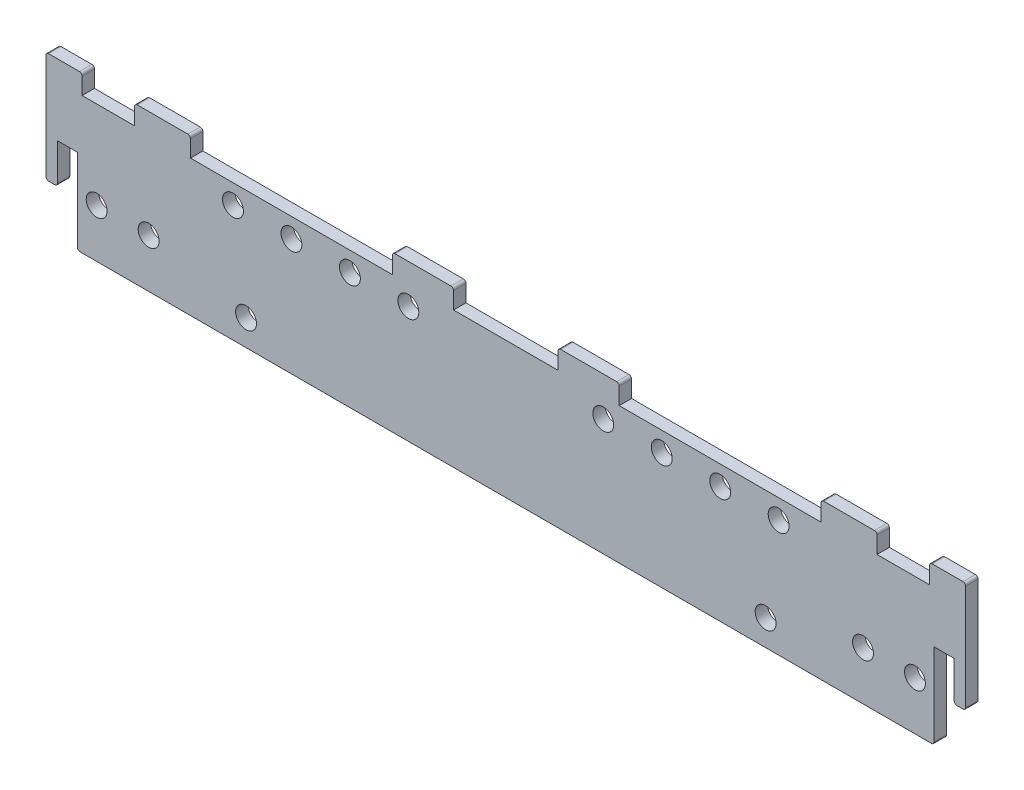
from build123d import *

# Parameters (mm, degrees)
SKETCH41_R                  = 2.5527
BACK_PLATE_EXTRUDE_DEPTH    = 3.0226
SKETCH71_W                  = 8.89
SKETCH71_H                  = 4.7625
SKETCH71_W_2                = 13.79855
SKETCH71_W_3                = 15.09395
BOSS_EXTRUDE26_DEPTH        = 3.0226
SKETCH91_W                  = 4.9022
SKETCH91_H                  = 20.7645
SKETCH91_W_2                = 12.8524
SKETCH91_H_2                = 4.7625
SKETCH91_W_3                = 49.3649
SKETCH91_W_4                = 12.7762
BACK_PLATE_TOLERENCES_DEPTH = 4.0226
FILLET27_R                  = 0.635
FILLET28_R                  = 0.635


with BuildPart() as part:
    # Sketch41 → Back Plate Extrude (new body)
    with BuildSketch(Plane.XY.offset(152.527)):
        Polygon((-104.775, -7.9375), (-104.775, 12.7), (-109.5248, 12.7), (-109.5248, 3.175), (-112.395, 3.175), (-112.395, 25.4), (-104.775, 25.4), (104.775, 25.4), (112.395, 25.4), (112.395, 3.175), (109.5248, 3.175), (109.5248, 12.7), (104.775, 12.7), (104.775, -7.9375), align=None)
        with Locations((-100.0125, 3.9624)):
            Circle(SKETCH41_R, mode=Mode.SUBTRACT)
        with Locations((100.0125, 3.9624)):
            Circle(SKETCH41_R, mode=Mode.SUBTRACT)
        with Locations((23.8252, 20.6375)):
            Circle(SKETCH41_R, mode=Mode.SUBTRACT)
        with Locations((38.1127, 20.6375)):
            Circle(SKETCH41_R, mode=Mode.SUBTRACT)
        with Locations((52.4002, 20.6375)):
            Circle(SKETCH41_R, mode=Mode.SUBTRACT)
        with Locations((66.6877, 20.6375)):
            Circle(SKETCH41_R, mode=Mode.SUBTRACT)
        with Locations((-66.6877, 20.6375)):
            Circle(SKETCH41_R, mode=Mode.SUBTRACT)
        with Locations((-52.4002, 20.6375)):
            Circle(SKETCH41_R, mode=Mode.SUBTRACT)
        with Locations((-38.1127, 20.6375)):
            Circle(SKETCH41_R, mode=Mode.SUBTRACT)
        with Locations((-23.8252, 20.6375)):
            Circle(SKETCH41_R, mode=Mode.SUBTRACT)
        with Locations((-87.3125, 3.9624)):
            Circle(SKETCH41_R, mode=Mode.SUBTRACT)
        with Locations((87.3125, 3.9624)):
            Circle(SKETCH41_R, mode=Mode.SUBTRACT)
        with Locations((-63.5, -1.5875)):
            Circle(SKETCH41_R, mode=Mode.SUBTRACT)
        with Locations((63.5, -1.5875)):
            Circle(SKETCH41_R, mode=Mode.SUBTRACT)
    extrude(amount=BACK_PLATE_EXTRUDE_DEPTH)

    # Sketch71 → Boss-Extrude26 (add, through all)
    with BuildSketch(Plane.XY.offset(155.5496)):
        with Locations((-107.95, 27.78125)):
            Rectangle(SKETCH71_W, SKETCH71_H)
        with Locations((-83.905725, 27.78125)):
            Rectangle(SKETCH71_W_2, SKETCH71_H)
        with Locations((-20.246975, 27.78125)):
            Rectangle(SKETCH71_W_3, SKETCH71_H)
    boss_extrude26 = extrude(amount=-BOSS_EXTRUDE26_DEPTH)

    # Mirror23: Boss-Extrude26 across plane
    add(boss_extrude26.mirror(Plane(origin=(0, 0, 0), x_dir=(0, 0, 1), z_dir=(1, 0, 0))))

    # Sketch91 → Back Plate Tolerences (cut, through all)
    with BuildSketch(Plane(origin=(0, 0, 152.527), x_dir=(-1, 0, 0), z_dir=(0, 0, -1))):
        with Locations((-107.1499, 2.44475)):
            Rectangle(SKETCH91_W, SKETCH91_H)
        with Locations((-97.155, 27.78125)):
            Rectangle(SKETCH91_W_2, SKETCH91_H_2)
        with Locations((-52.4002, 27.78125)):
            Rectangle(SKETCH91_W_3, SKETCH91_H_2)
        with Locations((-6.3881, 27.78125)):
            Rectangle(SKETCH91_W_4, SKETCH91_H_2)
    back_plate_tolerences = extrude(amount=-BACK_PLATE_TOLERENCES_DEPTH, mode=Mode.SUBTRACT)

    # Mirror25: Back Plate Tolerences across plane
    add(back_plate_tolerences.mirror(Plane(origin=(0, 0, 0), x_dir=(0, 0, 1), z_dir=(1, 0, 0))), mode=Mode.SUBTRACT)

    # Fillet27
    fillet27_edges = [part.edges().sort_by_distance(p)[0] for p in [
        (-112.395, 30.1625, 154.0383),
        (112.395, 30.1625, 154.0383),
        (109.601, 3.175, 154.0383),
        (104.6988, -7.9375, 154.0383),
        (-112.395, 3.175, 154.0383),
        (112.395, 3.175, 154.0383),
        (-109.601, 3.175, 154.0383),
        (-104.6988, -7.9375, 154.0383),
    ]]
    fillet(fillet27_edges, radius=FILLET27_R)

    # Fillet28
    fillet28_edges = [part.edges().sort_by_distance(p)[0] for p in [
        (103.5812, 30.1625, 154.0383),
        (90.7288, 30.1625, 154.0383),
        (77.08265, 30.1625, 154.0383),
        (27.71775, 30.1625, 154.0383),
        (12.7762, 30.1625, 154.0383),
        (-103.5812, 30.1625, 154.0383),
        (-90.7288, 30.1625, 154.0383),
        (-27.71775, 30.1625, 154.0383),
        (-77.08265, 30.1625, 154.0383),
        (-12.7762, 30.1625, 154.0383),
    ]]
    fillet(fillet28_edges, radius=FILLET28_R)


solid = part.part
